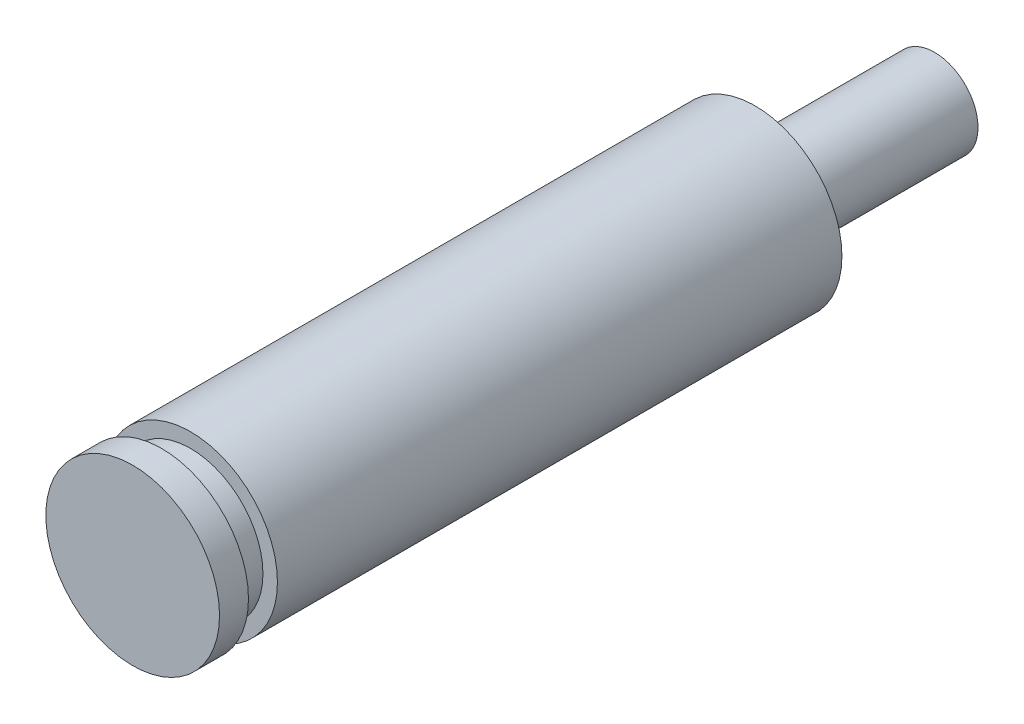
from build123d import *


with BuildPart() as part:
    # Sketch1 → Revolve1 (revolve)
    with BuildSketch(Plane(origin=(0, 0, 0), x_dir=(1, 0, 0), z_dir=(0, 1, 0))):
        Polygon((0, 0), (0, 27.7), (1.5, 27.7), (1.5, 21.5), (3, 21.5), (3, 2), (2.5, 2), (2.5, 1), (3, 1), (3, 0), align=None)
    revolve(axis=Axis((0, 0, 0), (0, 0, -1)))


solid = part.part
